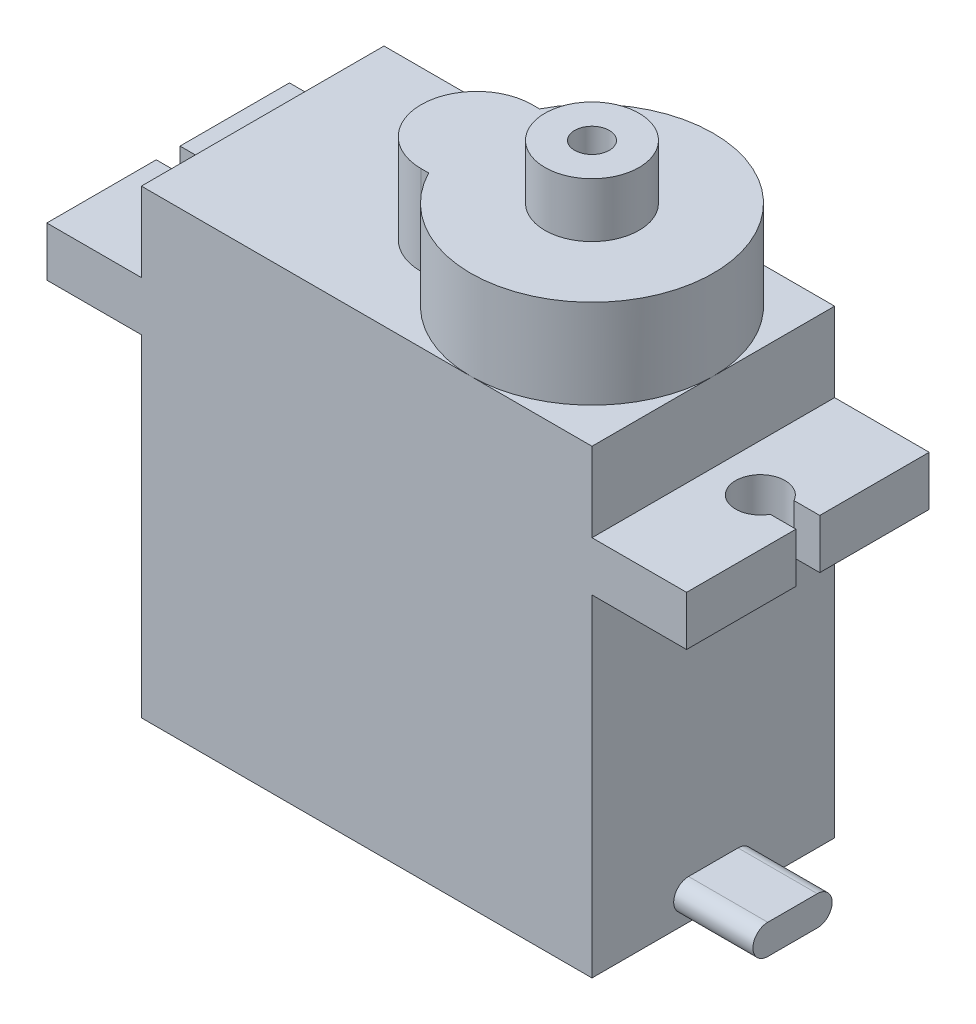
from build123d import *

# Parameters (mm, degrees)
SKETCH1_W           = 22.75
SKETCH1_H           = 12.25
BOSS_EXTRUDE1_DEPTH = 16.75
BOSS_EXTRUDE2_DEPTH = 2.5
CUT_EXTRUDE1_DEPTH  = 1
SKETCH5_W           = 22.75
SKETCH5_H           = 12.25
BOSS_EXTRUDE3_DEPTH = 4
BOSS_EXTRUDE4_DEPTH = 4.5
SKETCH7_R           = 2.375
SKETCH7_R_2         = 0.875
BOSS_EXTRUDE5_DEPTH = 2.75
BOSS_EXTRUDE6_DEPTH = 4


with BuildPart() as part:
    # Sketch1 → Boss-Extrude1 (new body)
    with BuildSketch(Plane(origin=(0, 0, 0), x_dir=(1, 0, 0), z_dir=(0, 1, 0))):
        Rectangle(SKETCH1_W, SKETCH1_H)
    extrude(amount=BOSS_EXTRUDE1_DEPTH)

    # Sketch3 → Boss-Extrude2 (add)
    with BuildSketch(Plane(origin=(0, 16.75, 0), x_dir=(1, 0, 0), z_dir=(0, 1, 0))):
        with BuildLine():
            Line((-16.15, -6.125), (16.15, -6.125))
            Line((16.15, -6.125), (16.15, -0.6))
            Line((16.15, -0.6), (14.84658561, -0.6))
            ThreePointArc((14.84658561, -0.6), (12.5, 0), (14.84658561, 0.6))
            Line((14.84658561, 0.6), (16.15, 0.6))
            Line((16.15, 0.6), (16.15, 6.125))
            Line((16.15, 6.125), (-16.15, 6.125))
            Line((-16.15, 6.125), (-16.15, 0.6))
            Line((-16.15, 0.6), (-14.84658561, 0.6))
            ThreePointArc((-14.84658561, 0.6), (-12.5, 0), (-14.84658561, -0.6))
            Line((-14.84658561, -0.6), (-16.15, -0.6))
            Line((-16.15, -0.6), (-16.15, -6.125))
        make_face()
    extrude(amount=BOSS_EXTRUDE2_DEPTH)

    # Sketch4 → Cut-Extrude1 (cut)
    with BuildSketch(Plane.XZ.offset(-16.75)):
        with BuildLine():
            Line((-11.375, -5.125), (-15.15, -5.125))
            Line((-15.15, -5.125), (-15.15, -1.761391495))
            ThreePointArc((-15.15, -1.761391495), (-11.5, 0), (-15.15, 1.761391495))
            Line((-15.15, 1.761391495), (-15.15, 5.125))
            Line((-15.15, 5.125), (-11.375, 5.125))
            Line((-11.375, 5.125), (-11.375, -5.125))
        make_face()
        with BuildLine():
            Line((11.375, 5.125), (11.375, -5.125))
            Line((11.375, -5.125), (15.15, -5.125))
            Line((15.15, -5.125), (15.15, -1.761391495))
            ThreePointArc((15.15, -1.761391495), (11.5, 0), (15.15, 1.761391495))
            Line((15.15, 1.761391495), (15.15, 5.125))
            Line((15.15, 5.125), (11.375, 5.125))
        make_face()
    extrude(amount=-CUT_EXTRUDE1_DEPTH, mode=Mode.SUBTRACT)

    # Sketch5 → Boss-Extrude3 (add)
    with BuildSketch(Plane(origin=(0, 19.25, 0), x_dir=(1, 0, 0), z_dir=(0, 1, 0))):
        Rectangle(SKETCH5_W, SKETCH5_H)
    extrude(amount=BOSS_EXTRUDE3_DEPTH)

    # Sketch6 → Boss-Extrude4 (add)
    with BuildSketch(Plane(origin=(0, 23.25, 0), x_dir=(1, 0, 0), z_dir=(0, 1, 0))):
        with BuildLine():
            Line((-0.575, 2.8), (-0.197533846, 2.8))
            ThreePointArc((-0.197533846, 2.8), (11.375, 0), (-0.197533846, -2.8))
            Line((-0.197533846, -2.8), (-0.575, -2.8))
            ThreePointArc((-0.575, -2.8), (-3.375, 0), (-0.575, 2.8))
        make_face()
    extrude(amount=BOSS_EXTRUDE4_DEPTH)

    # Sketch7 → Boss-Extrude5 (add)
    with BuildSketch(Plane(origin=(0, 27.75, 0), x_dir=(1, 0, 0), z_dir=(0, 1, 0))):
        with Locations((5.25, 0)):
            Circle(SKETCH7_R)
        with Locations((5.25, 0)):
            Circle(SKETCH7_R_2, mode=Mode.SUBTRACT)
    extrude(amount=BOSS_EXTRUDE5_DEPTH)

    # Sketch8 → Boss-Extrude6 (add)
    with BuildSketch(Plane(origin=(11.375, 0, 0), x_dir=(0, 0, -1), z_dir=(1, 0, 0))):
        with BuildLine():
            Line((-1.25, 2), (1.25, 2))
            ThreePointArc((1.25, 2), (2, 1.25), (1.25, 0.5))
            Line((1.25, 0.5), (-1.25, 0.5))
            ThreePointArc((-1.25, 0.5), (-2, 1.25), (-1.25, 2))
        make_face()
    extrude(amount=BOSS_EXTRUDE6_DEPTH)


solid = part.part
